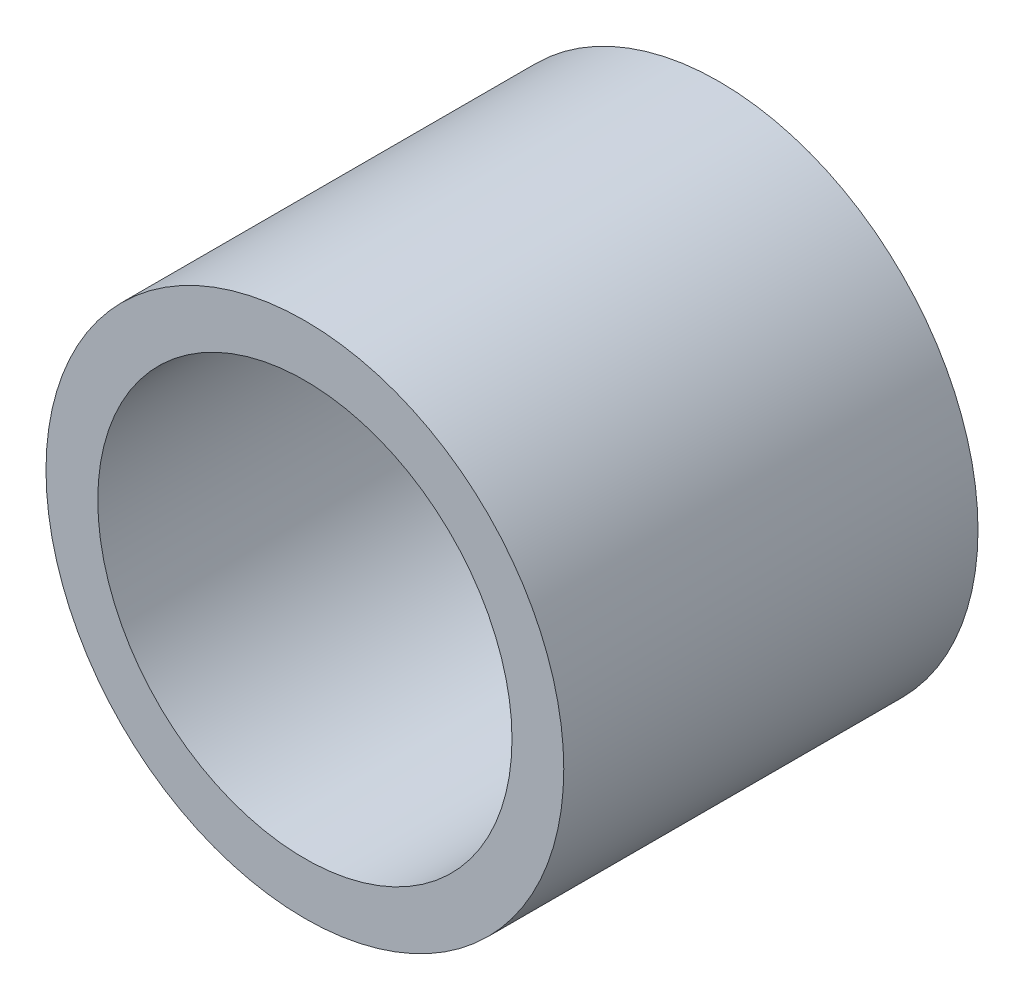
from build123d import *

# Parameters (mm, degrees)
SKETCH1_R      = 7.9375
SKETCH1_R_2    = 6.35
EXTRUDE1_DEPTH = 6.35


with BuildPart() as part:
    # Sketch1 → Extrude1 (new body, symmetric)
    with BuildSketch(Plane.XY):
        Circle(SKETCH1_R)
        Circle(SKETCH1_R_2, mode=Mode.SUBTRACT)
    extrude(amount=EXTRUDE1_DEPTH, both=True)


solid = part.part
